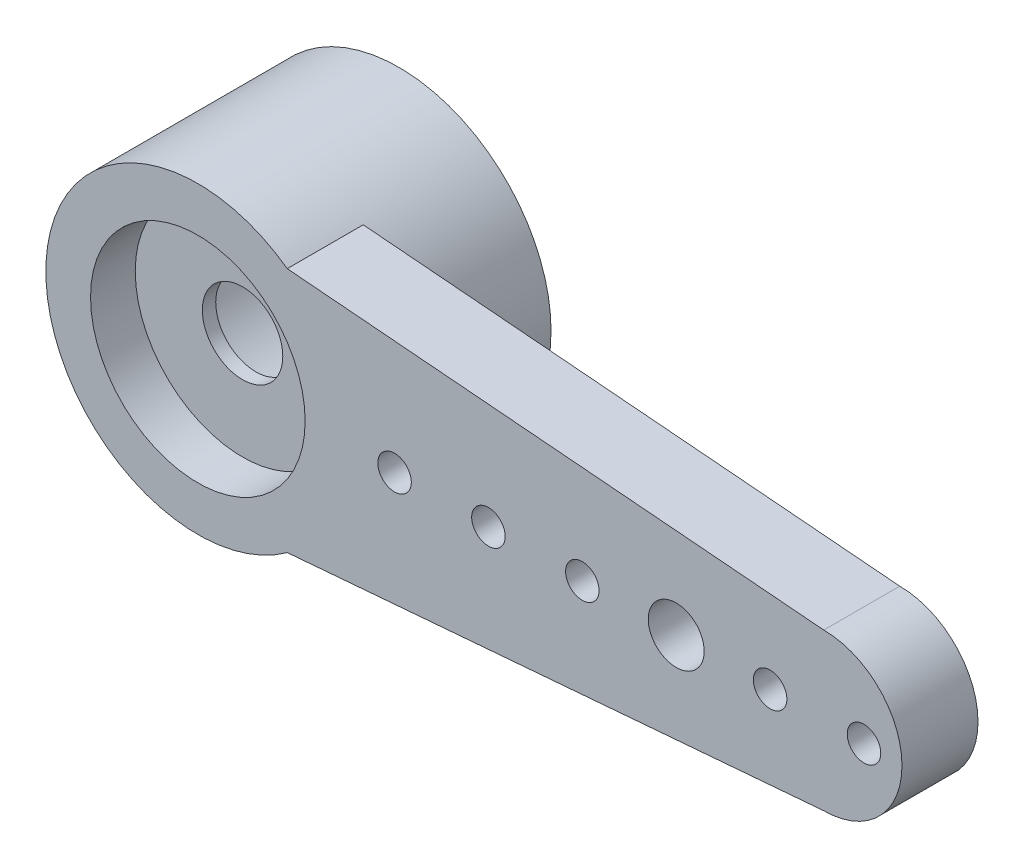
from build123d import *

# Parameters (mm, degrees)
SKICA1_R                 = 3.4
P_IDAT_VYSUNUT_M1_DEPTH  = 4.5
SKICA2_R                 = 2.25
ODEBRAT_VYSUNUT_M1_DEPTH = 3.2
SKICA3_R                 = 2.4
ODEBRAT_VYSUNUT_M2_DEPTH = 1
SKICA4_R                 = 0.9
ODEBRAT_VYSUNUT_M3_DEPTH = 0.3
P_IDAT_VYSUNUT_M2_DEPTH  = 1.7
SKICA6_R                 = 0.375
ODEBRAT_VYSUNUT_M4_DEPTH = 1.7
LINPOLE1_COUNT           = 6
LINPOLE1_PITCH           = 2.1
SKICA7_R                 = 0.625
ODEBRAT_VYSUNUT_M5_DEPTH = 1.7


with BuildPart() as part:
    # Skica1 → Přidat vysunutím1 (new body)
    with BuildSketch(Plane.XY):
        Circle(SKICA1_R)
    extrude(amount=P_IDAT_VYSUNUT_M1_DEPTH)

    # Skica2 → Odebrat vysunutím1 (cut)
    with BuildSketch(Plane(origin=(0, 0, 0), x_dir=(-1, 0, 0), z_dir=(0, 0, -1))):
        Circle(SKICA2_R)
    extrude(amount=-ODEBRAT_VYSUNUT_M1_DEPTH, mode=Mode.SUBTRACT)

    # Skica3 → Odebrat vysunutím2 (cut)
    with BuildSketch(Plane.XY.offset(4.5)):
        Circle(SKICA3_R)
    extrude(amount=-ODEBRAT_VYSUNUT_M2_DEPTH, mode=Mode.SUBTRACT)

    # Skica4 → Odebrat vysunutím3 (cut)
    with BuildSketch(Plane.XY.offset(3.5)):
        Circle(SKICA4_R)
    extrude(amount=-ODEBRAT_VYSUNUT_M3_DEPTH, mode=Mode.SUBTRACT)

    # Skica5 → Přidat vysunutím2 (add)
    with BuildSketch(Plane.XY.offset(4.5)):
        with BuildLine():
            Line((1.999374902, -2.75), (14, -1.75))
            ThreePointArc((14, -1.75), (15.75, 0), (14, 1.75))
            Line((14, 1.75), (1.999374902, 2.75))
            ThreePointArc((1.999374902, 2.75), (3.4, 0), (1.999374902, -2.75))
        make_face()
    extrude(amount=-P_IDAT_VYSUNUT_M2_DEPTH)

    # Skica6 → Odebrat vysunutím4 (cut)
    with BuildSketch(Plane.XY.offset(4.5)):
        with Locations((4.4, 0)):
            Circle(SKICA6_R)
    odebrat_vysunut_m4 = extrude(amount=-ODEBRAT_VYSUNUT_M4_DEPTH, mode=Mode.SUBTRACT)

    # LinPole1: Odebrat vysunutím4 ×6
    with Locations(*[(i * LINPOLE1_PITCH, 0, 0) for i in range(1, LINPOLE1_COUNT)]):
        add(odebrat_vysunut_m4, mode=Mode.SUBTRACT)

    # Skica7 → Odebrat vysunutím5 (cut)
    with BuildSketch(Plane.XY.offset(4.5)):
        with Locations((10.7, 0)):
            Circle(SKICA7_R)
    extrude(amount=-ODEBRAT_VYSUNUT_M5_DEPTH, mode=Mode.SUBTRACT)


solid = part.part
